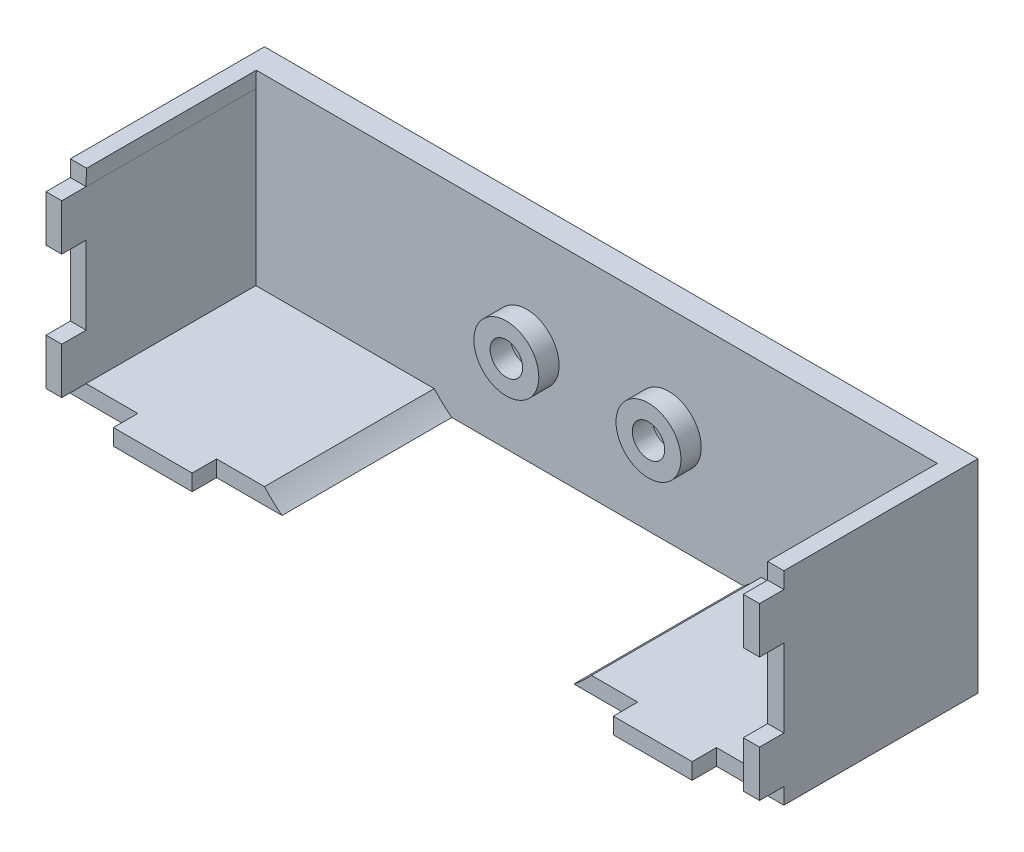
from build123d import *

# Parameters (mm, degrees)
ESBO_O1_W                = 87.854335153
ESBO_O1_H                = 25
RESSALTO_EXTRUS_O1_DEPTH = 3
ESBO_O1_11_R             = 4
ESBO_O1_11_R_2           = 2
RESSALTO_EXTRUS_O2_DEPTH = 5.5
RESSALTO_EXTRUS_O3_DEPTH = 23.9
ESBO_O1_13_W             = 9.7
ESBO_O1_13_H             = 2
ESBO_O1_13_W_2           = 1.938437843
ESBO_O1_13_H_2           = 5.7
ESBO_O1_13_W_3           = 2
RESSALTO_EXTRUS_O4_DEPTH = 26.9


with BuildPart() as part:
    # Esboço1 → Ressalto-extrusão1 (new body)
    with BuildSketch(Plane.XY):
        with Locations((33.001638151, 1.832173033)):
            Rectangle(ESBO_O1_W, ESBO_O1_H)
    extrude(amount=RESSALTO_EXTRUS_O1_DEPTH)

    # Esboço1<11> → Ressalto-extrusão2 (add)
    # profile 1 of 2: a face of its own
    with BuildSketch(Plane.XY):
        with Locations((24.354470574, 1.482173033)):
            Circle(ESBO_O1_11_R)
        with Locations((24.354470574, 1.482173033)):
            Circle(ESBO_O1_11_R_2, mode=Mode.SUBTRACT)
    # profile 2 of 2: a face of its own
    with BuildSketch(Plane.XY):
        with Locations((41.854470574, 1.482173033)):
            Circle(ESBO_O1_11_R)
        with Locations((41.854470574, 1.482173033)):
            Circle(ESBO_O1_11_R_2, mode=Mode.SUBTRACT)
    extrude(amount=RESSALTO_EXTRUS_O2_DEPTH)

    # Esboço1<12> → Ressalto-extrusão3 (add)
    with BuildSketch(Plane.XY):
        with BuildLine():
            ThreePointArc((15.138180648, -10.667826967), (14.007108736, -9.720264336), (12.972906533, -8.667826967))
            Line((12.972906533, -8.667826967), (-8.987091583, -8.667826967))
            Line((-8.987091583, -8.667826967), (-8.987091583, 12.332173033))
            ThreePointArc((-8.987091583, 12.332173033), (-8.9716974, 13.332646658), (-8.925529426, 14.332173033))
            Line((-8.925529426, 14.332173033), (-10.925529426, 14.332173033))
            Line((-10.925529426, 14.332173033), (-10.925529426, -10.667826967))
            Line((-10.925529426, -10.667826967), (15.138180648, -10.667826967))
        make_face()
        with BuildLine():
            ThreePointArc((53.236034614, -8.667826967), (52.201832411, -9.720264336), (51.0707605, -10.667826967))
            Line((51.0707605, -10.667826967), (76.928805727, -10.667826967))
            Line((76.928805727, -10.667826967), (76.928805727, 14.332173033))
            Line((76.928805727, 14.332173033), (74.928805727, 14.332173033))
            Line((74.928805727, 14.332173033), (74.928805727, -8.667826967))
            Line((74.928805727, -8.667826967), (53.236034614, -8.667826967))
        make_face()
    extrude(amount=RESSALTO_EXTRUS_O3_DEPTH)

    # Esboço1<13> → Ressalto-extrusão4 (add)
    with BuildSketch(Plane.XY):
        with Locations((2.224470574, -9.667826967)):
            Rectangle(ESBO_O1_13_W, ESBO_O1_13_H)
        with Locations((-9.956310504, -5.817826967)):
            Rectangle(ESBO_O1_13_W_2, ESBO_O1_13_H_2)
        with Locations((63.778805727, -9.667826967)):
            Rectangle(ESBO_O1_13_W, ESBO_O1_13_H)
        with Locations((-9.956310504, 9.482173033)):
            Rectangle(ESBO_O1_13_W_2, ESBO_O1_13_H_2)
        with Locations((75.928805727, -5.817826967)):
            Rectangle(ESBO_O1_13_W_3, ESBO_O1_13_H_2)
        with Locations((75.928805727, 9.482173033)):
            Rectangle(ESBO_O1_13_W_3, ESBO_O1_13_H_2)
    extrude(amount=RESSALTO_EXTRUS_O4_DEPTH)


solid = part.part
